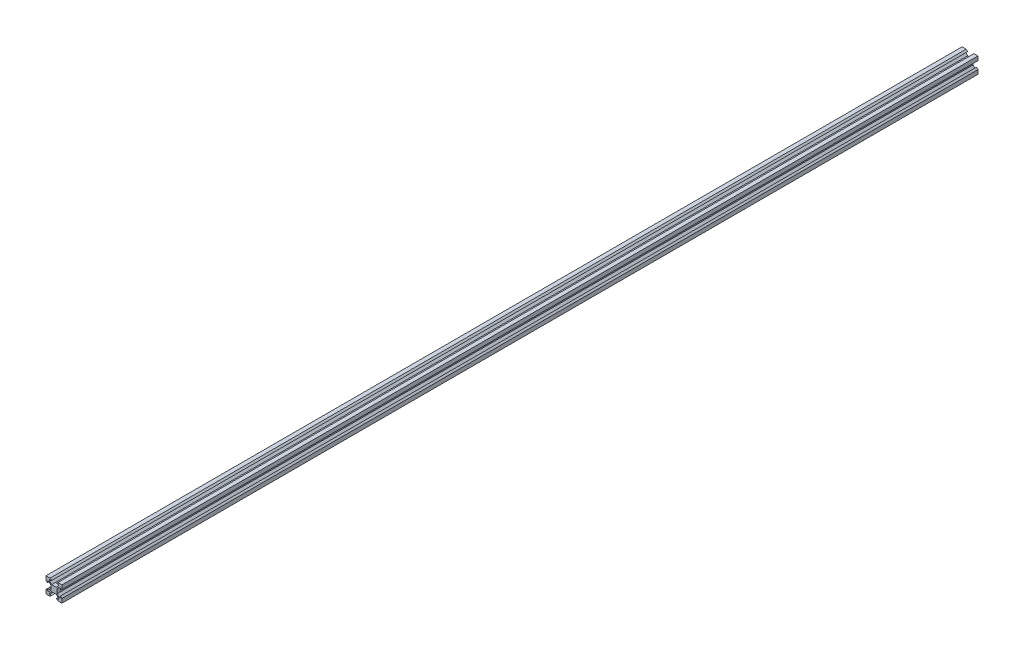
from build123d import *

# Parameters (mm, degrees)
SKETCH1_W           = 20
SKETCH1_H           = 20
BOSS_EXTRUDE1_DEPTH = 1153.3
CUT_EXTRUDE1_DEPTH  = 1154.3


with BuildPart() as part:
    # Sketch1 → Boss-Extrude1 (new body)
    with BuildSketch(Plane.XY):
        with Locations((10, 10)):
            Rectangle(SKETCH1_W, SKETCH1_H)
    extrude(amount=BOSS_EXTRUDE1_DEPTH)

    # Sketch2 → Cut-Extrude1 (cut, through all)
    with BuildSketch(Plane.XY.offset(1153.3)):
        Polygon((4.5, 18.18), (6.94, 18.18), (5.12, 20), (14.88, 20), (13.06, 18.18), (15.5, 18.18), (15.5, 16.475807358), (12.834192642, 13.81), (7.165807358, 13.81), (4.5, 16.475807358), align=None)
        Polygon((14.88, 0), (13.06, 1.82), (15.5, 1.82), (15.5, 3.524192642), (12.834192642, 6.19), (7.165807358, 6.19), (4.5, 3.524192642), (4.5, 1.82), (6.94, 1.82), (5.12, 0), align=None)
        Polygon((1.82, 4.5), (1.82, 6.94), (0, 5.12), (0, 14.88), (1.82, 13.06), (1.82, 15.5), (3.524192642, 15.5), (6.19, 12.834192642), (6.19, 7.165807358), (3.524192642, 4.5), align=None)
        Polygon((20, 14.88), (18.18, 13.06), (18.18, 15.5), (16.475807358, 15.5), (13.81, 12.834192642), (13.81, 7.165807358), (16.475807358, 4.5), (18.18, 4.5), (18.18, 6.94), (20, 5.12), align=None)
    extrude(amount=-CUT_EXTRUDE1_DEPTH, mode=Mode.SUBTRACT)


solid = part.part
